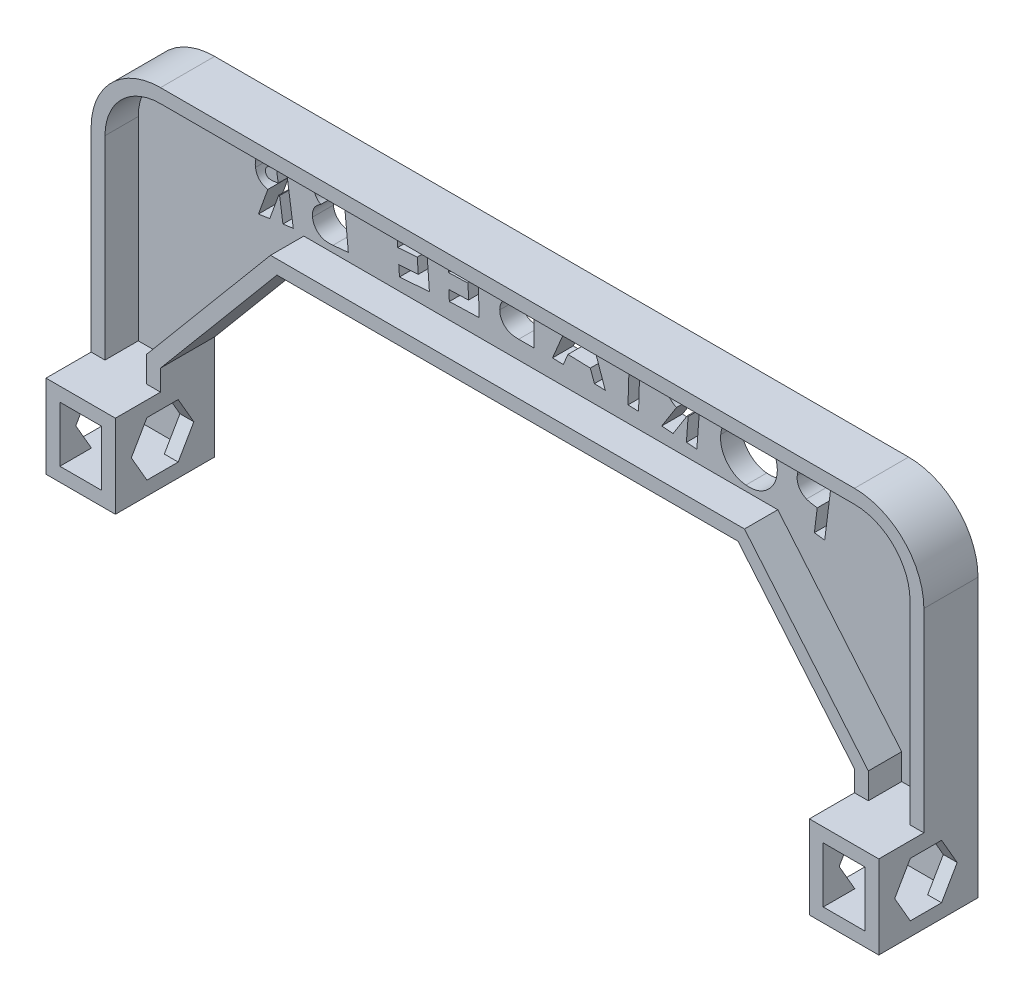
from build123d import *

# Parameters (mm, degrees)
RESSALTO_EXTRUS_O1_DEPTH      = 3
ESBO_O1_4_W                   = 2
ESBO_O1_4_H                   = 2
ESBO_O1_4_W_2                 = 6
ESBO_O1_4_H_2                 = 8
RESSALTO_EXTRUS_O2_DEPTH      = 7.8
RESSALTO_EXTRUS_O3_START      = 7.8
ESBO_O1_5_W                   = 2
ESBO_O1_5_H                   = 8
ESBO_O1_5_H_2                 = 2
ESBO_O1_5_W_2                 = 6
RESSALTO_EXTRUS_O3_DEPTH      = 6.5
RESSALTO_EXTRUS_O3_DEPTH_BACK = 1
CORTE_EXTRUS_O1_DEPTH         = 126.815301136
CORTE_EXTRUS_O2_DEPTH         = 90.8


with BuildPart() as part:
    # Esboço1 → Ressalto-extrusão1 (new body)
    with BuildSketch(Plane.XY):
        with BuildLine():
            Line((-50, -20), (-33.218007376, 0))
            Line((-33.218007376, 0), (33.218007376, 0))
            Line((33.218007376, 0), (50, -20))
            Line((50, -20), (50, -35))
            Line((50, -35), (60, -35))
            Line((60, -35), (60, 5))
            ThreePointArc((60, 5), (57.071067812, 12.071067812), (50, 15))
            Line((50, 15), (-50, 15))
            ThreePointArc((-50, 15), (-57.071067812, 12.071067812), (-60, 5))
            Line((-60, 5), (-60, -35))
            Line((-60, -35), (-50, -35))
            Line((-50, -35), (-50, -20))
        make_face()
    extrude(amount=RESSALTO_EXTRUS_O1_DEPTH)

    # Esboço1<4> → Ressalto-extrusão2 (add)
    with BuildSketch(Plane.XY):
        Polygon((-52, -35), (-52, -33), (-58, -33), (-60, -33), (-60, -35), align=None)
        with Locations((-51, -34)):
            Rectangle(ESBO_O1_4_W, ESBO_O1_4_H)
        with Locations((-55, -24)):
            Rectangle(ESBO_O1_4_W_2, ESBO_O1_4_H)
        with Locations((-51, -24)):
            Rectangle(ESBO_O1_4_W, ESBO_O1_4_H)
        with Locations((-59, -24)):
            Rectangle(ESBO_O1_4_W, ESBO_O1_4_H)
        Polygon((-52, -23), (-50, -23), (-50, -20), (-33.218007376, 0), (33.218007376, 0), (50, -20), (50, -23), (52, -23), (52, -19.272059531), (34.150622693, 2), (-34.150622693, 2), (-52, -19.272059531), align=None)
        with BuildLine():
            Line((-60, -23), (-58, -23))
            Line((-58, -23), (-58, 5))
            ThreePointArc((-58, 5), (-55.656854249, 10.656854249), (-50, 13))
            Line((-50, 13), (50, 13))
            ThreePointArc((50, 13), (55.656854249, 10.656854249), (58, 5))
            Line((58, 5), (58, -23))
            Line((58, -23), (60, -23))
            Line((60, -23), (60, 5))
            ThreePointArc((60, 5), (57.071067812, 12.071067812), (50, 15))
            Line((50, 15), (-50, 15))
            ThreePointArc((-50, 15), (-57.071067812, 12.071067812), (-60, 5))
            Line((-60, 5), (-60, -23))
        make_face()
        with Locations((59, -24)):
            Rectangle(ESBO_O1_4_W, ESBO_O1_4_H)
        with Locations((51, -24)):
            Rectangle(ESBO_O1_4_W, ESBO_O1_4_H)
        with Locations((51, -34)):
            Rectangle(ESBO_O1_4_W, ESBO_O1_4_H)
        Polygon((58, -33), (52, -33), (52, -35), (60, -35), (60, -33), align=None)
        with Locations((55, -24)):
            Rectangle(ESBO_O1_4_W_2, ESBO_O1_4_H)
        with Locations((-51, -29)):
            Rectangle(ESBO_O1_4_W, ESBO_O1_4_H_2)
        with Locations((-59, -29)):
            Rectangle(ESBO_O1_4_W, ESBO_O1_4_H_2)
        with Locations((59, -29)):
            Rectangle(ESBO_O1_4_W, ESBO_O1_4_H_2)
        with Locations((51, -29)):
            Rectangle(ESBO_O1_4_W, ESBO_O1_4_H_2)
    extrude(amount=RESSALTO_EXTRUS_O2_DEPTH)

    # Esboço1<5> → Ressalto-extrusão3 (add, two sides)
    with BuildSketch(Plane.XY.offset(RESSALTO_EXTRUS_O3_START)) as ressalto_extrus_o3_sk:
        with Locations((-59, -29)):
            Rectangle(ESBO_O1_5_W, ESBO_O1_5_H)
        Polygon((-52, -35), (-52, -33), (-58, -33), (-60, -33), (-60, -35), align=None)
        with Locations((-51, -34)):
            Rectangle(ESBO_O1_5_W, ESBO_O1_5_H_2)
        with Locations((-51, -24)):
            Rectangle(ESBO_O1_5_W, ESBO_O1_5_H_2)
        with Locations((-55, -24)):
            Rectangle(ESBO_O1_5_W_2, ESBO_O1_5_H_2)
        with Locations((-59, -24)):
            Rectangle(ESBO_O1_5_W, ESBO_O1_5_H_2)
        with Locations((-51, -29)):
            Rectangle(ESBO_O1_5_W, ESBO_O1_5_H)
        Polygon((58, -33), (52, -33), (52, -35), (60, -35), (60, -33), align=None)
        with Locations((51, -34)):
            Rectangle(ESBO_O1_5_W, ESBO_O1_5_H_2)
        with Locations((51, -29)):
            Rectangle(ESBO_O1_5_W, ESBO_O1_5_H)
        with Locations((51, -24)):
            Rectangle(ESBO_O1_5_W, ESBO_O1_5_H_2)
        with Locations((59, -29)):
            Rectangle(ESBO_O1_5_W, ESBO_O1_5_H)
        with Locations((59, -24)):
            Rectangle(ESBO_O1_5_W, ESBO_O1_5_H_2)
        with Locations((55, -24)):
            Rectangle(ESBO_O1_5_W_2, ESBO_O1_5_H_2)
    extrude(amount=RESSALTO_EXTRUS_O3_DEPTH)
    extrude(ressalto_extrus_o3_sk.sketch, amount=-RESSALTO_EXTRUS_O3_DEPTH_BACK)

    # Esboço2 → Corte-extrusão1 (cut, through all)
    with BuildSketch(Plane.ZY.offset(60)):
        Polygon((5.25166605, -33), (9.75499815, -33), (12.006664199, -29.1), (9.75499815, -25.2), (5.25166605, -25.2), (3, -29.1), align=None)
    extrude(amount=-CORTE_EXTRUS_O1_DEPTH, mode=Mode.SUBTRACT)

    # Esboço3 → Corte-extrusão2 (cut)
    with BuildSketch(Plane(origin=(0, 0, 0), x_dir=(-1, 0, 0), z_dir=(0, 0, -1))):
        with BuildLine():
            Line((-41.896423037, 9.401075985), (-40.315919231, 9.601421538))
            add(Edge.make_bspline(
                [(-40.315919231, 9.601421538), (-40.212622918, 9.61361694), (-40.013679353, 9.637104678), (-39.725764122, 9.662399451), (-39.459107933, 9.679258046), (-39.214000056, 9.684474181), (-38.989543328, 9.67818038), (-38.786781444, 9.662751179), (-38.604691446, 9.638785855), (-38.442287588, 9.600990263), (-38.293343571, 9.554430977), (-38.153590669, 9.497194941), (-38.020540203, 9.429514852), (-37.893275269, 9.353407174), (-37.771635101, 9.267271822), (-37.657358944, 9.170343744), (-37.549996855, 9.062408694), (-37.448994914, 8.945559022), (-37.354905329, 8.820003898), (-37.2703278, 8.686017447), (-37.196009469, 8.543591818), (-37.128156108, 8.394556447), (-37.074024651, 8.236333853), (-37.024638253, 8.071928231), (-36.989160731, 7.898226013), (-36.971501891, 7.779316049), (-36.962516286, 7.718809358)],
                knots=[0, 0, 0, 0, 1.691021873, 3.256824111, 4.698480615, 6.03440271, 7.24130839, 8.347675884, 9.339669365, 10.22389208, 11.055131812, 11.874449479, 12.676037939, 13.479985174, 14.283378026, 15.096554989, 15.913058215, 16.756139501, 17.605800949, 18.461688381, 19.328995332, 20.216194319, 21.121045378, 22.04550277, 23.005464667, 24, 24, 24, 24], degree=3))
            add(Edge.make_bspline(
                [(-36.962516286, 7.718809358), (-36.954954388, 7.651574285), (-36.940159544, 7.520028955), (-36.938693987, 7.324910574), (-36.946295636, 7.137082691), (-36.973208452, 6.956570725), (-37.010179343, 6.782115501), (-37.064736918, 6.615133224), (-37.13350649, 6.45499292), (-37.216388711, 6.302515947), (-37.311536452, 6.157722517), (-37.419257593, 6.022809892), (-37.534300311, 5.893800707), (-37.665448695, 5.779040662), (-37.802414704, 5.667741281), (-37.953811034, 5.569940325), (-38.113996346, 5.478124962), (-38.22772988, 5.426644089), (-38.285432953, 5.400525104)],
                knots=[0, 0, 0, 0, 1.124235297, 2.199564857, 3.240841467, 4.246642947, 5.230269257, 6.202937811, 7.162259479, 8.124451015, 9.085067205, 10.038908266, 10.993359838, 11.954339799, 12.932939193, 13.925330682, 14.947409873, 16, 16, 16, 16], degree=3))
            add(Edge.make_bspline(
                [(-38.285432953, 5.400525104), (-38.323436818, 5.385772486), (-38.406461206, 5.353543472), (-38.544677562, 5.311568244), (-38.705220402, 5.271214104), (-38.887840936, 5.228940872), (-39.093283933, 5.190371481), (-39.321206478, 5.152022593), (-39.571554939, 5.115865108), (-39.74612686, 5.092914623), (-39.837315965, 5.080926245)],
                knots=[0, 0, 0, 0, 0.615908378, 1.345532002, 2.180878653, 3.117422677, 4.177753009, 5.339148604, 6.610081985, 8, 8, 8, 8], degree=3))
            Line((-39.837315965, 5.080926245), (-39.419134375, 1.768864447))
            Line((-39.419134375, 1.768864447), (-40.909005669, 1.579649202))
            Line((-40.909005669, 1.579649202), (-41.896423037, 9.401075985))
        make_face()
        with BuildLine():
            Line((-40.020171034, 6.532636482), (-39.547927945, 6.591468112))
            add(Edge.make_bspline(
                [(-39.547927945, 6.591468112), (-39.461900487, 6.60319378), (-39.304068101, 6.624706564), (-39.090282803, 6.667907333), (-38.919161636, 6.711412598), (-38.786572516, 6.763055473), (-38.683445967, 6.825309214), (-38.599255396, 6.897708832), (-38.525463883, 6.979353765), (-38.468913946, 7.07431822), (-38.424755467, 7.178307059), (-38.400165923, 7.291434635), (-38.391943097, 7.412014127), (-38.399283578, 7.493585982), (-38.403096214, 7.53595429)],
                knots=[0, 0, 0, 0, 1.833142917, 3.363220631, 4.604138048, 5.558217951, 6.356811558, 7.135063587, 7.896387994, 8.670038046, 9.457890586, 10.272560963, 11.102770582, 12, 12, 12, 12], degree=3))
            add(Edge.make_bspline(
                [(-38.403096214, 7.53595429), (-38.408499626, 7.5722066), (-38.419052288, 7.643006003), (-38.450412829, 7.74274874), (-38.487702162, 7.834953442), (-38.537465353, 7.917247333), (-38.599108511, 7.988496194), (-38.667630333, 8.053793014), (-38.748282409, 8.107845464), (-38.807133627, 8.136614321), (-38.837178245, 8.151301346)],
                knots=[0, 0, 0, 0, 1.110279981, 2.1683352, 3.162778682, 4.122425314, 5.069461417, 6.013763577, 6.985990132, 8, 8, 8, 8], degree=3))
            add(Edge.make_bspline(
                [(-38.837178245, 8.151301346), (-38.861889841, 8.160951888), (-38.915025771, 8.181702897), (-39.004538874, 8.200710863), (-39.105956883, 8.21548756), (-39.220853851, 8.220237933), (-39.34818315, 8.222988965), (-39.488665915, 8.214782749), (-39.642092517, 8.20490308), (-39.748327475, 8.191635695), (-39.80392504, 8.184692271)],
                knots=[0, 0, 0, 0, 0.650943487, 1.399686532, 2.241429132, 3.167605182, 4.222636089, 5.369938562, 6.62356973, 8, 8, 8, 8], degree=3))
            Line((-39.80392504, 8.184692271), (-40.223696675, 8.132220817))
            Line((-40.223696675, 8.132220817), (-40.020171034, 6.532636482))
        make_face(mode=Mode.SUBTRACT)
        with BuildLine():
            add(Edge.make_bspline(
                [(-30.386568734, 11.000273626), (-30.250427759, 11.010562549), (-29.981393609, 11.030894941), (-29.580709085, 11.011185074), (-29.190583799, 10.956593861), (-28.811565942, 10.860490759), (-28.444208392, 10.724287003), (-28.087801503, 10.549361583), (-27.741254813, 10.337123959), (-27.411083503, 10.087389632), (-27.10245526, 9.810147571), (-26.825917201, 9.508327252), (-26.584196733, 9.186116757), (-26.379961526, 8.842657514), (-26.211937271, 8.479091069), (-26.080298221, 8.095429647), (-25.981199682, 7.692081315), (-25.947011074, 7.4141432), (-25.929675204, 7.273210325)],
                knots=[0, 0, 0, 0, 1.013394438, 2.002613188, 2.973155381, 3.935742307, 4.901191689, 5.878490946, 6.88060172, 7.915333596, 8.949593424, 9.958426538, 10.951422752, 11.936613552, 12.921371528, 13.9212444, 14.945934409, 16, 16, 16, 16], degree=3))
            add(Edge.make_bspline(
                [(-25.929675204, 7.273210325), (-25.919044608, 7.132847095), (-25.898114507, 6.856492254), (-25.913279594, 6.445676471), (-25.96730189, 6.04786434), (-26.059818203, 5.662620281), (-26.190898117, 5.290190215), (-26.360624937, 4.930779545), (-26.56846262, 4.583753995), (-26.813870076, 4.254887522), (-27.085699165, 3.948784521), (-27.380683336, 3.674673507), (-27.693801475, 3.433873464), (-28.03054796, 3.234368259), (-28.383423468, 3.064636887), (-28.757750932, 2.93548184), (-29.150488513, 2.83793215), (-29.420938615, 2.803550191), (-29.558155773, 2.786105958)],
                knots=[0, 0, 0, 0, 1.050946507, 2.069161232, 3.064224875, 4.045709242, 5.023737272, 6.008538498, 7.010134941, 8.040411196, 9.0696141, 10.064204968, 11.044602543, 12.014283487, 12.983074794, 13.964838655, 14.967428548, 16, 16, 16, 16], degree=3))
            add(Edge.make_bspline(
                [(-29.558155773, 2.786105958), (-29.702238889, 2.775287259), (-29.984998291, 2.75405584), (-30.404753864, 2.771679062), (-30.810003755, 2.82571317), (-31.199713692, 2.924142732), (-31.575471453, 3.059620381), (-31.935086562, 3.237439165), (-32.281428802, 3.453386559), (-32.606899175, 3.708318399), (-32.908427037, 3.990556335), (-33.178690209, 4.293639945), (-33.414264767, 4.614813132), (-33.613761402, 4.95486659), (-33.777920942, 5.313159043), (-33.909071613, 5.688080747), (-34.004390044, 6.081798937), (-34.037830636, 6.352134214), (-34.054800404, 6.489318598)],
                knots=[0, 0, 0, 0, 1.067942814, 2.09581025, 3.100976414, 4.086969804, 5.06296796, 6.050051845, 7.048621755, 8.07668355, 9.102889961, 10.099765446, 11.075991904, 12.044187863, 13.010723604, 13.986469781, 14.978213631, 16, 16, 16, 16], degree=3))
            add(Edge.make_bspline(
                [(-34.054800404, 6.489318598), (-34.062438398, 6.582011284), (-34.07760953, 6.766124162), (-34.077679654, 7.041251323), (-34.064764223, 7.312764386), (-34.030680348, 7.579906503), (-33.979964878, 7.842892259), (-33.911127222, 8.10152256), (-33.825004416, 8.356440568), (-33.722081657, 8.606651102), (-33.60322303, 8.849462365), (-33.469289927, 9.08174277), (-33.322365794, 9.303822595), (-33.162443503, 9.515575409), (-32.985928652, 9.714790963), (-32.797548044, 9.904058867), (-32.593835774, 10.081019231), (-32.379062031, 10.247832842), (-32.1523929, 10.398776293), (-31.919890321, 10.53731768), (-31.679011042, 10.655919788), (-31.432879886, 10.759636123), (-31.180600266, 10.846058547), (-30.921672882, 10.914132269), (-30.656705073, 10.967215448), (-30.476845653, 10.989225906), (-30.386568734, 11.000273626)],
                knots=[0, 0, 0, 0, 1.035409782, 2.056605373, 3.061480869, 4.060862921, 5.052966719, 6.042327367, 7.039108653, 8.047583756, 9.053377683, 10.047639012, 11.031561243, 12.01734085, 13.000200147, 13.993584996, 14.989212094, 16.003406253, 17.020070963, 18.020271989, 19.015479049, 20.007600406, 20.993203272, 21.98256392, 22.987387404, 24, 24, 24, 24], degree=3))
        make_face()
        with BuildLine():
            add(Edge.make_bspline(
                [(-30.257775164, 9.542203213), (-30.346031051, 9.531145436), (-30.519795801, 9.509374062), (-30.77255922, 9.448465178), (-31.011562264, 9.363207888), (-31.239206251, 9.259085573), (-31.451607997, 9.128587543), (-31.651425835, 8.976861092), (-31.83803026, 8.802347369), (-32.010516151, 8.607920619), (-32.163766019, 8.396676884), (-32.29350631, 8.172253559), (-32.399273012, 7.938060363), (-32.478297145, 7.692418227), (-32.536777644, 7.437203431), (-32.567100227, 7.170737895), (-32.576578984, 6.89393711), (-32.561495532, 6.707093755), (-32.553798802, 6.611751991)],
                knots=[0, 0, 0, 0, 1.02515846, 2.01840818, 2.99077065, 3.947856573, 4.899658472, 5.859278178, 6.83664155, 7.841148597, 8.852235353, 9.840829116, 10.82571261, 11.809533457, 12.811918421, 13.83993352, 14.897768949, 16, 16, 16, 16], degree=3))
            add(Edge.make_bspline(
                [(-32.553798802, 6.611751991), (-32.54057733, 6.506439479), (-32.514760687, 6.300803101), (-32.440572839, 6.004315647), (-32.339130604, 5.727877545), (-32.208909778, 5.471931206), (-32.054701568, 5.233989659), (-31.869319988, 5.018208246), (-31.657894268, 4.821115878), (-31.498888592, 4.709328798), (-31.418507336, 4.652817696)],
                knots=[0, 0, 0, 0, 1.085209989, 2.119013661, 3.119333083, 4.091866215, 5.051492141, 6.013215044, 6.995631636, 8, 8, 8, 8], degree=3))
            add(Edge.make_bspline(
                [(-31.418507336, 4.652817696), (-31.352811072, 4.612126786), (-31.223022565, 4.531738462), (-31.020199225, 4.428485233), (-30.811154475, 4.348770631), (-30.598677078, 4.28292982), (-30.380414018, 4.241722087), (-30.157850077, 4.21480743), (-29.930503394, 4.210619324), (-29.778060188, 4.221303319), (-29.701259739, 4.226685885)],
                knots=[0, 0, 0, 0, 1.027249077, 2.029417139, 3.020047742, 3.998751259, 4.982742711, 5.968725566, 6.976649783, 8, 8, 8, 8], degree=3))
            add(Edge.make_bspline(
                [(-29.701259739, 4.226685885), (-29.614586974, 4.237738052), (-29.443959768, 4.259495755), (-29.195958821, 4.32047529), (-28.960971062, 4.405778374), (-28.737088979, 4.511397479), (-28.527646797, 4.64452898), (-28.328258941, 4.796265532), (-28.142760845, 4.973626307), (-27.971057395, 5.170310975), (-27.818096949, 5.383497296), (-27.686369353, 5.607232825), (-27.579380887, 5.840608085), (-27.496302777, 6.082829028), (-27.438547941, 6.333860264), (-27.408171807, 6.593366845), (-27.396621179, 6.861628133), (-27.410759632, 7.042704266), (-27.417956454, 7.13487649)],
                knots=[0, 0, 0, 0, 1.017745659, 2.003571691, 2.968842961, 3.927589305, 4.882267401, 5.855863607, 6.843371954, 7.867862736, 8.894734499, 9.896971141, 10.889278626, 11.88164379, 12.876639419, 13.884949358, 14.92338698, 16, 16, 16, 16], degree=3))
            add(Edge.make_bspline(
                [(-27.417956454, 7.13487649), (-27.429490578, 7.225809621), (-27.452275548, 7.40544257), (-27.515686342, 7.665895799), (-27.597111052, 7.91444208), (-27.705609243, 8.148037591), (-27.833867182, 8.369751916), (-27.98643864, 8.577551191), (-28.160615476, 8.772385093), (-28.354936174, 8.951580826), (-28.562999857, 9.113959979), (-28.783472263, 9.250099593), (-29.009653356, 9.365229458), (-29.245537936, 9.450563608), (-29.487683989, 9.513382171), (-29.738173597, 9.549723906), (-29.996141647, 9.561764601), (-30.169842408, 9.548777626), (-30.257775164, 9.542203213)],
                knots=[0, 0, 0, 0, 1.060838713, 2.09562328, 3.099203713, 4.0852851, 5.072836584, 6.061208079, 7.065464122, 8.094918476, 9.118922886, 10.117063104, 11.091613226, 12.052927382, 13.01619941, 13.984154173, 14.979515815, 16, 16, 16, 16], degree=3))
        make_face(mode=Mode.SUBTRACT)
        with BuildLine():
            Line((-23.065533422, 11.609534018), (-21.47071922, 11.72719728))
            add(Edge.make_bspline(
                [(-21.47071922, 11.72719728), (-21.365272536, 11.734010828), (-21.162433794, 11.747117466), (-20.869786003, 11.758749345), (-20.600383868, 11.760663307), (-20.35367812, 11.753344176), (-20.129827522, 11.735816203), (-19.928407467, 11.711448588), (-19.750405981, 11.676839352), (-19.592303401, 11.633650185), (-19.449118176, 11.579386286), (-19.313891827, 11.516783098), (-19.186783438, 11.44025516), (-19.063171181, 11.358374812), (-18.94686838, 11.263885528), (-18.837330711, 11.158650165), (-18.73372962, 11.043849456), (-18.637090476, 10.920022317), (-18.547615776, 10.788154306), (-18.468641352, 10.647977411), (-18.397625768, 10.501375527), (-18.33971843, 10.346619114), (-18.289704071, 10.185990075), (-18.252097615, 10.017841023), (-18.223085726, 9.843183597), (-18.211986227, 9.723831829), (-18.206358743, 9.663320076)],
                knots=[0, 0, 0, 0, 1.710999419, 3.29130286, 4.741753383, 6.072716902, 7.286511842, 8.376577652, 9.356174742, 10.220316028, 11.026924402, 11.833167424, 12.62948255, 13.426906879, 14.232464417, 15.051937303, 15.884429834, 16.734260524, 17.593572376, 18.462219521, 19.337455739, 20.228455733, 21.135189148, 22.05958146, 23.016201187, 24, 24, 24, 24], degree=3))
            add(Edge.make_bspline(
                [(-18.206358743, 9.663320076), (-18.203022948, 9.599748342), (-18.196464867, 9.474768082), (-18.19851586, 9.290234483), (-18.217797532, 9.113134542), (-18.242844403, 8.941933596), (-18.285304981, 8.77857768), (-18.337098881, 8.621780868), (-18.402992205, 8.472916558), (-18.481007835, 8.331643957), (-18.570512246, 8.196343162), (-18.674140381, 8.069901056), (-18.789459774, 7.949682089), (-18.917240138, 7.836642663), (-19.05706335, 7.730450738), (-19.209130939, 7.630850501), (-19.374660338, 7.540929244), (-19.490811025, 7.486983831), (-19.549945982, 7.459518994)],
                knots=[0, 0, 0, 0, 1.098417839, 2.159458913, 3.179587141, 4.170434415, 5.141973883, 6.087687081, 7.017209411, 7.94637174, 8.869664381, 9.812365746, 10.763194758, 11.741426294, 12.752950208, 13.790435782, 14.875060593, 16, 16, 16, 16], degree=3))
            Line((-19.549945982, 7.459518994), (-17.42405706, 4.087035521))
            Line((-17.42405706, 4.087035521), (-19.066572585, 3.966192171))
            Line((-19.066572585, 3.966192171), (-21.087518599, 7.179671238))
            Line((-21.087518599, 7.179671238), (-21.227442477, 7.170130973))
            Line((-21.227442477, 7.170130973), (-20.98257569, 3.826268293))
            Line((-20.98257569, 3.826268293), (-22.485167337, 3.714965208))
            Line((-22.485167337, 3.714965208), (-23.065533422, 11.609534018))
        make_face()
        with BuildLine():
            Line((-21.335565474, 8.634561562), (-20.863322385, 8.669542532))
            add(Edge.make_bspline(
                [(-20.863322385, 8.669542532), (-20.806028314, 8.674356407), (-20.695465643, 8.683645935), (-20.537547426, 8.704785693), (-20.392861661, 8.727622398), (-20.263302911, 8.75763017), (-20.14788976, 8.792405014), (-20.047140819, 8.83185279), (-19.960407045, 8.876076237), (-19.865048855, 8.941140215), (-19.767998123, 9.042629196), (-19.692811317, 9.196191983), (-19.654207714, 9.376853454), (-19.658803783, 9.504679335), (-19.661249067, 9.572687564)],
                knots=[0, 0, 0, 0, 1.194174899, 2.304447325, 3.309022753, 4.23576798, 5.064674109, 5.810926827, 6.480643779, 7.082281881, 8.203797721, 9.351066959, 10.590666896, 12, 12, 12, 12], degree=3))
            add(Edge.make_bspline(
                [(-19.661249067, 9.572687564), (-19.665897413, 9.614220236), (-19.67497153, 9.695296874), (-19.708197459, 9.811351776), (-19.761060073, 9.915818838), (-19.825277447, 10.011917358), (-19.905305783, 10.094187629), (-19.995894364, 10.163609576), (-20.096547943, 10.220496522), (-20.191097014, 10.252503677), (-20.274803214, 10.274375949), (-20.35058279, 10.284472998), (-20.437575355, 10.292318233), (-20.53625661, 10.296852169), (-20.64601282, 10.298187542), (-20.767462706, 10.296910816), (-20.900499021, 10.289950917), (-20.993186075, 10.283574541), (-21.041407321, 10.280257175)],
                knots=[0, 0, 0, 0, 1.130975968, 2.207797541, 3.248006932, 4.291382272, 5.327123176, 6.340836291, 7.375581577, 8.442788479, 9.034768356, 9.717019784, 10.509945318, 11.401159294, 12.391939176, 13.483212824, 14.690619603, 16, 16, 16, 16], degree=3))
            Line((-21.041407321, 10.280257175), (-21.454818779, 10.250046338))
            Line((-21.454818779, 10.250046338), (-21.335565474, 8.634561562))
        make_face(mode=Mode.SUBTRACT)
        Polygon((-15.737490532, 12.091769339), (-11.374409603, 12.230103173), (-11.326708281, 10.748182099), (-12.765698165, 10.703660865), (-12.563762568, 4.291013129), (-14.087024787, 4.241721763), (-14.288960384, 10.654369499), (-15.68978921, 10.609848265), align=None)
        Polygon((-6.496203073, 12.463071705), (-4.971350809, 12.510773027), (-1.684729716, 4.711606861), (-3.246152993, 4.662315495), (-3.913971503, 6.269850051), (-7.133810745, 6.16808723), (-7.726897184, 4.520801573), (-9.289910505, 4.471510207), align=None)
        Polygon((-5.656659804, 10.392834325), (-6.621816555, 7.650008304), (-4.524548426, 7.716790155), align=None, mode=Mode.SUBTRACT)
        with BuildLine():
            Line((0.974172601, 4.613549552), (0.988482998, 12.508118362))
            Line((0.988482998, 12.508118362), (2.228717373, 12.506528318))
            add(Edge.make_bspline(
                [(2.228717373, 12.506528318), (2.315637803, 12.505610608), (2.48314053, 12.503842107), (2.725520149, 12.498989337), (2.949570122, 12.484358035), (3.15611268, 12.47240155), (3.344165793, 12.45052311), (3.514067245, 12.427671814), (3.666074557, 12.399766631), (3.760052733, 12.375084829), (3.804451047, 12.363424352)],
                knots=[0, 0, 0, 0, 1.31520351, 2.534503959, 3.66699256, 4.711949634, 5.663909293, 6.530325692, 7.305678562, 8, 8, 8, 8], degree=3))
            add(Edge.make_bspline(
                [(3.804451047, 12.363424352), (3.861916358, 12.346654238), (3.975425779, 12.31352876), (4.13968479, 12.251970966), (4.293632297, 12.177323952), (4.441600628, 12.098250485), (4.575905258, 12.002140415), (4.704780937, 11.901321093), (4.82210638, 11.787136469), (4.931720184, 11.665511637), (5.03055034, 11.535758537), (5.114512731, 11.398273247), (5.187000232, 11.256030613), (5.245418572, 11.107881198), (5.292544312, 10.954461506), (5.323547174, 10.794530265), (5.343262506, 10.629183576), (5.345607895, 10.516910368), (5.346793795, 10.460141599)],
                knots=[0, 0, 0, 0, 1.085110909, 2.143385454, 3.17493102, 4.185680808, 5.179898688, 6.164317401, 7.149720415, 8.143195094, 9.130984472, 10.101660835, 11.05994029, 12.021682026, 12.985293971, 13.965200427, 14.971143089, 16, 16, 16, 16], degree=3))
            add(Edge.make_bspline(
                [(5.346793795, 10.460141599), (5.344129084, 10.386875392), (5.338884693, 10.242680869), (5.304023981, 10.031375446), (5.242704927, 9.830770796), (5.15752185, 9.639468709), (5.046463116, 9.455394434), (4.90445082, 9.279985363), (4.732909845, 9.110270072), (4.60217722, 9.007660244), (4.534281275, 8.954369864)],
                knots=[0, 0, 0, 0, 0.986971374, 1.942448915, 2.875275639, 3.805393237, 4.756833964, 5.762633775, 6.838024613, 8, 8, 8, 8], degree=3))
            add(Edge.make_bspline(
                [(4.534281275, 8.954369864), (4.592444162, 8.925955333), (4.706742645, 8.870116669), (4.867774346, 8.775684252), (5.018709542, 8.679328713), (5.156082732, 8.57528432), (5.28093355, 8.465845635), (5.395526718, 8.35287306), (5.495408991, 8.232759821), (5.585467347, 8.108357595), (5.663179043, 7.977760157), (5.730431739, 7.841546432), (5.787313061, 7.700005262), (5.835723077, 7.553154971), (5.872294669, 7.399960132), (5.896855217, 7.240916644), (5.913890312, 7.076366505), (5.915308497, 6.964739737), (5.916029572, 6.907983146)],
                knots=[0, 0, 0, 0, 1.181987256, 2.32277587, 3.407639583, 4.451287442, 5.466759683, 6.438847684, 7.387117862, 8.316721247, 9.24152306, 10.159407327, 11.088859462, 12.025694097, 12.981397556, 13.961838054, 14.963697264, 16, 16, 16, 16], degree=3))
            add(Edge.make_bspline(
                [(5.916029572, 6.907983146), (5.911812173, 6.798985994), (5.903504911, 6.584287876), (5.835611467, 6.270503422), (5.726955944, 5.971673532), (5.575808473, 5.692236612), (5.392622852, 5.437631883), (5.18235181, 5.212966224), (4.945365194, 5.024354184), (4.727220027, 4.895974116), (4.538609453, 4.810142913), (4.38258402, 4.757687061), (4.214656529, 4.710304434), (4.03349893, 4.675776238), (3.840216858, 4.644053769), (3.633563786, 4.624879948), (3.414017459, 4.611209377), (3.263330249, 4.610654499), (3.185923903, 4.610369464)],
                knots=[0, 0, 0, 0, 1.296660825, 2.554109309, 3.803838537, 5.071506244, 6.323734345, 7.529051816, 8.723516779, 9.917264741, 10.533013316, 11.18760166, 11.875009221, 12.608898881, 13.381822739, 14.20627625, 15.078584036, 16, 16, 16, 16], degree=3))
            Line((3.185923903, 4.610369464), (0.974172601, 4.613549552))
        make_face()
        with BuildLine():
            Line((2.487894556, 11.072308566), (2.484714468, 9.407532425))
            Line((2.484714468, 9.407532425), (2.812263547, 9.407532425))
            add(Edge.make_bspline(
                [(2.812263547, 9.407532425), (2.897797225, 9.409908191), (3.058439727, 9.414370165), (3.282075101, 9.456412014), (3.471959582, 9.527443583), (3.626759302, 9.629251735), (3.747997229, 9.757073439), (3.830890983, 9.909313722), (3.884827719, 10.080243986), (3.889485992, 10.201591257), (3.891903471, 10.264566179)],
                knots=[0, 0, 0, 0, 1.310654006, 2.461565349, 3.472875083, 4.399397888, 5.279215998, 6.145260086, 7.037455906, 8, 8, 8, 8], degree=3))
            add(Edge.make_bspline(
                [(3.891903471, 10.264566179), (3.889929415, 10.323817844), (3.886138627, 10.437599076), (3.835203224, 10.597689407), (3.757197188, 10.740327287), (3.642097265, 10.859199964), (3.497370906, 10.957297934), (3.317763282, 11.024256843), (3.106677471, 11.065211863), (2.955051346, 11.069841964), (2.874275266, 11.072308566)],
                knots=[0, 0, 0, 0, 0.961249656, 1.845891933, 2.70775429, 3.586989994, 4.513468657, 5.532909129, 6.685701888, 8, 8, 8, 8], degree=3))
            Line((2.874275266, 11.072308566), (2.487894556, 11.072308566))
        make_face(mode=Mode.SUBTRACT)
        with BuildLine():
            Line((2.483124424, 8.067125273), (2.479944336, 6.042999171))
            Line((2.479944336, 6.042999171), (2.855194737, 6.042999171))
            add(Edge.make_bspline(
                [(2.855194737, 6.042999171), (2.929945458, 6.043385472), (3.07317886, 6.044125682), (3.278411959, 6.055836368), (3.464781432, 6.072341755), (3.632195765, 6.09723851), (3.780366574, 6.130599374), (3.910148559, 6.169461874), (4.021283663, 6.216475291), (4.113523464, 6.27347911), (4.191905349, 6.33630493), (4.256589403, 6.40717447), (4.313904653, 6.482582046), (4.35949924, 6.565883182), (4.397188852, 6.655647146), (4.421267803, 6.752781922), (4.438520065, 6.855960068), (4.43980541, 6.926984543), (4.440468675, 6.963634688)],
                knots=[0, 0, 0, 0, 1.717402168, 3.290795761, 4.722014614, 6.015563983, 7.176721534, 8.209132991, 9.125471181, 9.940095177, 10.693320529, 11.425779771, 12.139469348, 12.864601779, 13.601905114, 14.369950713, 15.158859782, 16, 16, 16, 16], degree=3))
            add(Edge.make_bspline(
                [(4.440468675, 6.963634688), (4.439131828, 7.005026152), (4.436514437, 7.086065819), (4.419449738, 7.204184514), (4.388237309, 7.315289847), (4.347556134, 7.420195507), (4.294304326, 7.518551607), (4.229122379, 7.609923103), (4.149332344, 7.692397257), (4.060489223, 7.771736582), (3.956194236, 7.841559056), (3.836877383, 7.902905256), (3.701229927, 7.952066267), (3.55082551, 7.996443001), (3.383772462, 8.026078317), (3.201371578, 8.050620606), (3.00328192, 8.064529109), (2.865814868, 8.066240725), (2.794773062, 8.067125273)],
                knots=[0, 0, 0, 0, 0.88477619, 1.732288789, 2.543041289, 3.346639249, 4.132310836, 4.927722526, 5.737128457, 6.580086136, 7.469275203, 8.41164543, 9.440535939, 10.548462558, 11.759330033, 13.061898805, 14.481614247, 16, 16, 16, 16], degree=3))
            Line((2.794773062, 8.067125273), (2.483124424, 8.067125273))
        make_face(mode=Mode.SUBTRACT)
        Polygon((9.136168876, 12.350756156), (13.446778351, 12.207652189), (13.399077029, 10.736861424), (10.581518936, 10.830674024), (10.533817614, 9.402814449), (13.351375707, 9.309001849), (13.302084341, 7.865241833), (10.484526248, 7.959054433), (10.416154353, 5.882456877), (13.233712446, 5.788644277), (13.18442108, 4.313083379), (8.873811605, 4.456187346), align=None)
        Polygon((16.6323343, 11.998913126), (20.942943775, 11.682494356), (20.834820778, 10.211703591), (18.017262685, 10.41840932), (17.912319777, 8.990549745), (20.72987787, 8.783844016), (20.623344917, 7.340084), (17.805786824, 7.546789729), (17.653142593, 5.470192173), (20.470700686, 5.263486443), (20.362577689, 3.787925546), (16.051968214, 4.104344316), align=None)
        with BuildLine():
            Line((27.733364599, 3.164650716), (28.493405664, 11.059219526))
            Line((28.493405664, 11.059219526), (29.733640039, 10.93996622))
            add(Edge.make_bspline(
                [(29.733640039, 10.93996622), (29.820610136, 10.931382785), (29.988381015, 10.91482479), (30.229979616, 10.884020988), (30.453318753, 10.85278478), (30.658083441, 10.818235416), (30.844084363, 10.779912165), (31.011857116, 10.740460721), (31.161433431, 10.698741453), (31.25337529, 10.664912041), (31.296653361, 10.648988156)],
                knots=[0, 0, 0, 0, 1.315747567, 2.538161205, 3.666716661, 4.711011658, 5.664123345, 6.525455915, 7.305915456, 8, 8, 8, 8], degree=3))
            add(Edge.make_bspline(
                [(31.296653361, 10.648988156), (31.35265496, 10.627013696), (31.463176977, 10.583645978), (31.620962861, 10.505214682), (31.768728588, 10.417360595), (31.908414279, 10.322610465), (32.035278287, 10.21560556), (32.151635872, 10.099804865), (32.261421199, 9.977900308), (32.356872902, 9.84402103), (32.443507712, 9.705085306), (32.514410879, 9.559656642), (32.574492888, 9.411309125), (32.618726405, 9.257177453), (32.650736853, 9.098765167), (32.668104871, 8.935908516), (32.671341863, 8.768852017), (32.663379914, 8.656629393), (32.659321129, 8.599421349)],
                knots=[0, 0, 0, 0, 1.085326853, 2.14194802, 3.175455539, 4.186361929, 5.184516489, 6.165286388, 7.147920338, 8.140928316, 9.128531311, 10.099597572, 11.056999527, 12.013540981, 12.98902569, 13.970355176, 14.965342222, 16, 16, 16, 16], degree=3))
            add(Edge.make_bspline(
                [(32.659321129, 8.599421349), (32.649977055, 8.525944854), (32.631685523, 8.382110619), (32.574178532, 8.174767169), (32.496847402, 7.97921453), (32.393487279, 7.795961752), (32.264738723, 7.6227936), (32.104099136, 7.46266669), (31.918195174, 7.306538143), (31.77694045, 7.216601068), (31.703704643, 7.169971729)],
                knots=[0, 0, 0, 0, 0.991654944, 1.941218507, 2.875214618, 3.803981709, 4.753093396, 5.757818116, 6.837504352, 8, 8, 8, 8], degree=3))
            add(Edge.make_bspline(
                [(31.703704643, 7.169971729), (31.75918942, 7.136090411), (31.868267528, 7.06948277), (32.022313552, 6.96193593), (32.162527414, 6.84863293), (32.289888126, 6.731803155), (32.407775246, 6.613519316), (32.508438094, 6.486526495), (32.60023626, 6.358739971), (32.676696793, 6.225019778), (32.742425093, 6.088007233), (32.796290309, 5.945233535), (32.841480964, 5.79840761), (32.872214194, 5.645933233), (32.895848008, 5.490000475), (32.903799562, 5.328290626), (32.905008981, 5.162059204), (32.89601286, 5.049880017), (32.891467563, 4.993201397)],
                knots=[0, 0, 0, 0, 1.181458355, 2.322641438, 3.411898611, 4.45520185, 5.463447671, 6.442886507, 7.397031918, 8.320684593, 9.238491307, 10.15629802, 11.091929832, 12.027164811, 12.980823786, 13.95551357, 14.967021661, 16, 16, 16, 16], degree=3))
            add(Edge.make_bspline(
                [(32.891467563, 4.993201397), (32.877133965, 4.884448832), (32.848934741, 4.670494325), (32.752256476, 4.362453745), (32.614353801, 4.074464929), (32.43829025, 3.808385137), (32.230812602, 3.571032861), (31.999200861, 3.36612599), (31.742983369, 3.202059217), (31.513976175, 3.092068797), (31.316437756, 3.026531494), (31.155789131, 2.987287063), (30.983152107, 2.957120257), (30.79886507, 2.936850965), (30.602491848, 2.926044305), (30.393931774, 2.924219002), (30.173312569, 2.934660735), (30.022464198, 2.94689941), (29.945115901, 2.953174854)],
                knots=[0, 0, 0, 0, 1.29812423, 2.553866463, 3.80699784, 5.07186683, 6.322870902, 7.533691169, 8.723736822, 9.918002655, 10.533801098, 11.187399384, 11.876241093, 12.609479405, 13.383378194, 14.206304304, 15.080273082, 16, 16, 16, 16], degree=3))
            Line((29.945115901, 2.953174854), (27.733364599, 3.164650716))
        make_face()
        with BuildLine():
            Line((29.857663477, 9.483485852), (29.697069026, 7.81870971))
            Line((29.697069026, 7.81870971), (30.024618104, 7.786908829))
            add(Edge.make_bspline(
                [(30.024618104, 7.786908829), (30.110462955, 7.781283195), (30.271340576, 7.770740472), (30.499035546, 7.792262797), (30.695806881, 7.844787453), (30.86078983, 7.931790392), (30.992458151, 8.04877138), (31.091912424, 8.190875886), (31.158638414, 8.357581931), (31.176213034, 8.477988827), (31.185350276, 8.540589718)],
                knots=[0, 0, 0, 0, 1.313130748, 2.460873872, 3.478955498, 4.406666163, 5.28451917, 6.14520026, 7.035668876, 8, 8, 8, 8], degree=3))
            add(Edge.make_bspline(
                [(31.185350276, 8.540589718), (31.188331808, 8.59949635), (31.194105186, 8.713561917), (31.16213596, 8.879576589), (31.09278061, 9.027741927), (30.992134322, 9.159950372), (30.85518954, 9.271121865), (30.682615281, 9.356780503), (30.475227536, 9.416766864), (30.324479117, 9.435388719), (30.244044186, 9.445324794)],
                knots=[0, 0, 0, 0, 0.953741382, 1.846804824, 2.707927439, 3.584344991, 4.518338035, 5.540451088, 6.687656896, 8, 8, 8, 8], degree=3))
            Line((30.244044186, 9.445324794), (29.857663477, 9.483485852))
        make_face(mode=Mode.SUBTRACT)
        with BuildLine():
            Line((29.568275456, 6.478302559), (29.374290079, 4.454176457))
            Line((29.374290079, 4.454176457), (29.74954048, 4.417605443))
            add(Edge.make_bspline(
                [(29.74954048, 4.417605443), (29.8242403, 4.411290347), (29.967676755, 4.39916428), (30.173950324, 4.389463915), (30.362453179, 4.387972321), (30.531613941, 4.400328541), (30.683457485, 4.415942919), (30.816701702, 4.444220484), (30.932022752, 4.481890318), (31.030638301, 4.528736141), (31.113562343, 4.585318319), (31.187193042, 4.648390924), (31.250044762, 4.720039402), (31.305490328, 4.798201595), (31.347886365, 4.885787218), (31.382980624, 4.97933516), (31.409120937, 5.081130543), (31.417783687, 5.152066154), (31.422266842, 5.188776817)],
                knots=[0, 0, 0, 0, 1.714256769, 3.291666748, 4.721947087, 6.021668619, 7.16881925, 8.210098808, 9.130019533, 9.937774334, 10.697540896, 11.419327017, 12.14910905, 12.872013826, 13.603806282, 14.367045639, 15.154911928, 16, 16, 16, 16], degree=3))
            add(Edge.make_bspline(
                [(31.422266842, 5.188776817), (31.42548494, 5.230107546), (31.431800162, 5.311215305), (31.422436639, 5.430605013), (31.404123428, 5.544883911), (31.371856286, 5.65375355), (31.327515446, 5.7576035), (31.269498716, 5.854762601), (31.200357142, 5.947137098), (31.117095571, 6.032469634), (31.020869125, 6.113783118), (30.906516589, 6.184992842), (30.775706126, 6.248254145), (30.628407072, 6.303057051), (30.465833607, 6.353380119), (30.285128842, 6.391377983), (30.08847645, 6.425528275), (29.951055521, 6.440395955), (29.879924094, 6.448091721)],
                knots=[0, 0, 0, 0, 0.880638692, 1.728172574, 2.540081331, 3.339285352, 4.137295403, 4.93594246, 5.741010823, 6.586291621, 7.466930312, 8.414736767, 9.443460788, 10.553331326, 11.755367577, 13.060299911, 14.478360877, 16, 16, 16, 16], degree=3))
            Line((29.879924094, 6.448091721), (29.568275456, 6.478302559))
        make_face(mode=Mode.SUBTRACT)
        with BuildLine():
            Line((36.797302075, 10.029344256), (38.376215837, 9.801967954))
            add(Edge.make_bspline(
                [(38.376215837, 9.801967954), (38.480185528, 9.78606179), (38.680552498, 9.755407955), (38.968410157, 9.702722345), (39.232305595, 9.648103175), (39.471645806, 9.58787516), (39.686433051, 9.522764711), (39.877265376, 9.45511195), (40.044270677, 9.384222723), (40.231471767, 9.283179979), (40.436784535, 9.137461346), (40.649245527, 8.928018616), (40.828653403, 8.683692065), (40.947605689, 8.455149058), (41.026011703, 8.259662361), (41.073148744, 8.105807368), (41.109954031, 7.947519065), (41.135836708, 7.784978492), (41.147927319, 7.61746405), (41.149387684, 7.445414584), (41.140157588, 7.268512409), (41.125099878, 7.149699721), (41.117451815, 7.089352769)],
                knots=[0, 0, 0, 0, 1.421702442, 2.739858206, 3.955317269, 5.063945027, 6.074777992, 6.988051197, 7.799921806, 8.524389552, 9.860299707, 11.187652424, 12.540363298, 13.940840087, 14.657937094, 15.385374562, 16.113552568, 16.853270248, 17.607725678, 18.381527536, 19.177950767, 20, 20, 20, 20], degree=3))
            add(Edge.make_bspline(
                [(41.117451815, 7.089352769), (41.107088667, 7.026665464), (41.08676405, 6.903720627), (41.043651087, 6.724536278), (40.989655906, 6.555189178), (40.926697913, 6.394285765), (40.849238274, 6.245558405), (40.764925028, 6.104010641), (40.670033265, 5.971818725), (40.56246698, 5.850955704), (40.446061586, 5.738577975), (40.318341848, 5.637140342), (40.180913014, 5.544173048), (40.032393672, 5.461452451), (39.873239783, 5.38863658), (39.703793905, 5.324858322), (39.523743431, 5.270416099), (39.398823662, 5.243003865), (39.335012412, 5.229001207)],
                knots=[0, 0, 0, 0, 1.098627607, 2.154672159, 3.183799504, 4.17104847, 5.138524667, 6.080166322, 7.018948283, 7.94765197, 8.874725716, 9.81382088, 10.764652966, 11.741334579, 12.750302423, 13.788816882, 14.870488153, 16, 16, 16, 16], degree=3))
            Line((39.335012412, 5.229001207), (40.683369783, 1.484447421))
            Line((40.683369783, 1.484447421), (39.056754699, 1.719773943))
            Line((39.056754699, 1.719773943), (37.773589134, 5.284652749))
            Line((37.773589134, 5.284652749), (37.636845344, 5.305323322))
            Line((37.636845344, 5.305323322), (37.159832123, 1.993261523))
            Line((37.159832123, 1.993261523), (35.669960829, 2.207917473))
            Line((35.669960829, 2.207917473), (36.797302075, 10.029344256))
        make_face()
        with BuildLine():
            Line((37.846731162, 6.757033559), (38.314204118, 6.688661664))
            add(Edge.make_bspline(
                [(38.314204118, 6.688661664), (38.371371879, 6.680564554), (38.481201251, 6.665008576), (38.640019547, 6.653438426), (38.785836493, 6.64595956), (38.918593127, 6.647367425), (39.038789343, 6.656301687), (39.145050413, 6.6738389), (39.239511954, 6.696805492), (39.346284684, 6.740698892), (39.461918642, 6.819815736), (39.567819745, 6.9531398), (39.643714118, 7.120318618), (39.667443023, 7.245461246), (39.680051975, 7.311958939)],
                knots=[0, 0, 0, 0, 1.201887753, 2.309038811, 3.314307394, 4.241418159, 5.071781453, 5.821109568, 6.482272192, 7.090969204, 8.217532052, 9.355122756, 10.594577754, 12, 12, 12, 12], degree=3))
            add(Edge.make_bspline(
                [(39.680051975, 7.311958939), (39.684443802, 7.353243246), (39.693055447, 7.434194931), (39.685136627, 7.554641951), (39.657616867, 7.66888705), (39.612763822, 7.776134162), (39.552451903, 7.8735986), (39.479956041, 7.962491392), (39.391287717, 8.035975472), (39.287332763, 8.104765652), (39.149879498, 8.161018549), (38.971211713, 8.211654149), (38.744558865, 8.258081601), (38.5772259, 8.28377042), (38.485928878, 8.297786263)],
                knots=[0, 0, 0, 0, 0.843790407, 1.654533199, 2.441982274, 3.225209468, 4.009549887, 4.767719369, 5.548044747, 6.343870394, 7.295605463, 8.554979076, 10.120393372, 12, 12, 12, 12], degree=3))
            Line((38.485928878, 8.297786263), (38.077287552, 8.356617894))
            Line((38.077287552, 8.356617894), (37.846731162, 6.757033559))
        make_face(mode=Mode.SUBTRACT)
    extrude(amount=-CORTE_EXTRUS_O2_DEPTH, mode=Mode.SUBTRACT)


with BuildPart() as corte_extrus_o2_piece_1:
    # of the separate pieces the step leaves, piece 1, a body of its own (corte_extrus_o2_pieces)
    add(part.part.solids().sort_by_distance((-60, 5, 7.8))[0])


with BuildPart() as corte_extrus_o2_piece_2:
    # of the separate pieces the step leaves, piece 2, a body of its own (corte_extrus_o2_pieces)
    add(part.part.solids().sort_by_distance((30.257775164, 9.542203213, 0))[0])


with BuildPart() as corte_extrus_o2_piece_3:
    # of the separate pieces the step leaves, piece 3, a body of its own (corte_extrus_o2_pieces)
    add(part.part.solids().sort_by_distance((-29.568275456, 6.478302559, 0))[0])


with BuildPart() as corte_extrus_o2_piece_4:
    # of the separate pieces the step leaves, piece 4, a body of its own (corte_extrus_o2_pieces)
    add(part.part.solids().sort_by_distance((-2.483124424, 8.067125273, 0))[0])


with BuildPart() as corte_extrus_o2_piece_5:
    # of the separate pieces the step leaves, piece 5, a body of its own (corte_extrus_o2_pieces)
    add(part.part.solids().sort_by_distance((5.656659804, 10.392834325, 0))[0])


with BuildPart() as corte_extrus_o2_piece_6:
    # of the separate pieces the step leaves, piece 6, a body of its own (corte_extrus_o2_pieces)
    add(part.part.solids().sort_by_distance((21.335565474, 8.634561562, 0))[0])


with BuildPart() as corte_extrus_o2_piece_7:
    # of the separate pieces the step leaves, piece 7, a body of its own (corte_extrus_o2_pieces)
    add(part.part.solids().sort_by_distance((-37.846731162, 6.757033559, 0))[0])


with BuildPart() as corte_extrus_o2_piece_8:
    # of the separate pieces the step leaves, piece 8, a body of its own (corte_extrus_o2_pieces)
    add(part.part.solids().sort_by_distance((40.020171034, 6.532636482, 0))[0])


with BuildPart() as corte_extrus_o2_piece_9:
    # of the separate pieces the step leaves, piece 9, a body of its own (corte_extrus_o2_pieces)
    add(part.part.solids().sort_by_distance((-29.857663477, 9.483485852, 0))[0])


with BuildPart() as corte_extrus_o2_piece_10:
    # of the separate pieces the step leaves, piece 10, a body of its own (corte_extrus_o2_pieces)
    add(part.part.solids().sort_by_distance((-2.487894556, 11.072308566, 0))[0])


solid = Compound([corte_extrus_o2_piece_1.part, corte_extrus_o2_piece_7.part])
